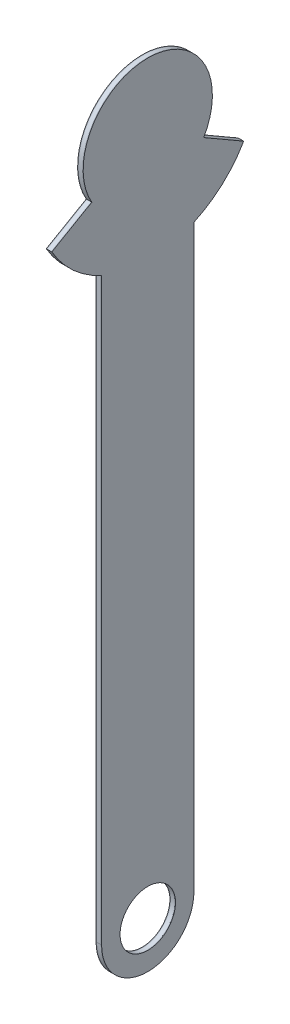
from build123d import *

# Parameters (mm, degrees)
SKETCH2_R           = 15
BOSS_EXTRUDE1_DEPTH = 0.25
SKETCH3_R           = 15
BOSS_EXTRUDE2_DEPTH = 2.5
SKETCH4_R           = 15
BOSS_EXTRUDE3_DEPTH = 0.25


with BuildPart() as part:
    # Sketch2 → Boss-Extrude1 (new body)
    with BuildSketch(Plane(origin=(0, 0, 0), x_dir=(0, 0, -1), z_dir=(1, 0, 0))):
        with BuildLine():
            Line((51.961524227, 166.8), (30.310889132, 179.3))
            ThreePointArc((30.310889132, 179.3), (0, 231.8), (-30.310889132, 179.3))
            Line((-30.310889132, 179.3), (-51.961524227, 166.8))
            ThreePointArc((-51.961524227, 166.8), (-40.390167668, 152.430704809), (-25, 142.256439427))
            Line((-25, 142.256439427), (-25, -171.8))
            ThreePointArc((-25, -171.8), (0, -196.8), (25, -171.8))
            Line((25, -171.8), (25, 142.256439427))
            ThreePointArc((25, 142.256439427), (40.390167668, 152.430704809), (51.961524227, 166.8))
        make_face()
        with Locations((0, -171.8)):
            Circle(SKETCH2_R, mode=Mode.SUBTRACT)
    extrude(amount=BOSS_EXTRUDE1_DEPTH)


with BuildPart() as body_2:
    # Sketch3 → Boss-Extrude2 (new body)
    with BuildSketch(Plane.ZY):
        with BuildLine():
            Line((51.961524227, 166.8), (30.310889132, 179.3))
            ThreePointArc((30.310889132, 179.3), (0, 231.8), (-30.310889132, 179.3))
            Line((-30.310889132, 179.3), (-51.961524227, 166.8))
            ThreePointArc((-51.961524227, 166.8), (-40.390167668, 152.430704809), (-25, 142.256439427))
            Line((-25, 142.256439427), (-25, -171.8))
            ThreePointArc((-25, -171.8), (0, -196.8), (25, -171.8))
            Line((25, -171.8), (25, 142.256439427))
            ThreePointArc((25, 142.256439427), (40.390167668, 152.430704809), (51.961524227, 166.8))
        make_face()
        with Locations((0, -171.8)):
            Circle(SKETCH3_R, mode=Mode.SUBTRACT)
    extrude(amount=BOSS_EXTRUDE2_DEPTH)


with BuildPart() as body_3:
    # Sketch4 → Boss-Extrude3 (new body)
    with BuildSketch(Plane.ZY.offset(2.5)):
        with BuildLine():
            ThreePointArc((25, 142.256439427), (40.390167668, 152.430704809), (51.961524227, 166.8))
            Line((51.961524227, 166.8), (30.310889132, 179.3))
            ThreePointArc((30.310889132, 179.3), (0, 231.8), (-30.310889132, 179.3))
            Line((-30.310889132, 179.3), (-51.961524227, 166.8))
            ThreePointArc((-51.961524227, 166.8), (-40.390167668, 152.430704809), (-25, 142.256439427))
            Line((-25, 142.256439427), (-25, -171.8))
            ThreePointArc((-25, -171.8), (0, -196.8), (25, -171.8))
            Line((25, -171.8), (25, 142.256439427))
        make_face()
        with Locations((0, -171.8)):
            Circle(SKETCH4_R, mode=Mode.SUBTRACT)
    extrude(amount=BOSS_EXTRUDE3_DEPTH)


solid = Compound([part.part, body_2.part, body_3.part])
